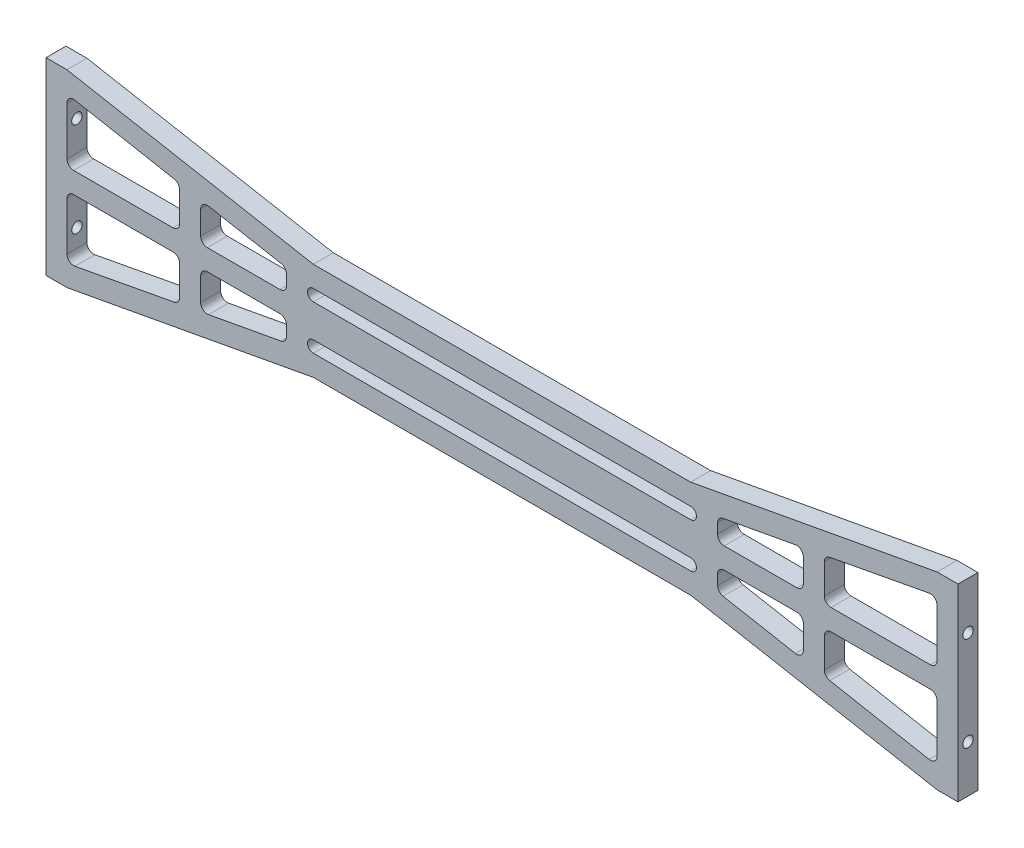
from build123d import *

# Parameters (mm, degrees)
BOSS_EXTRUDE1_DEPTH              = 4.763
TAP_DRILL_FOR_M3X0_5_TAP1_REACH  = 220.74
TAP_DRILL_FOR_M3X0_5_TAP1_BORE_R = 1.25
TAP_DRILL_FOR_M3X0_5_TAP2_REACH  = 220.74
TAP_DRILL_FOR_M3X0_5_TAP2_BORE_R = 1.25


with BuildPart() as part:
    # Sketch3 → Boss-Extrude1 (new body)
    with BuildSketch(Plane.XY):
        Polygon((-108.762998674, 22.483018567), (-108.762998674, -22.516981433), (-103.762998674, -22.516981433), (-45, -11.683163514), (45, -11.683163514), (103.762998674, -22.483018567), (108.762998674, -22.483018567), (108.762998674, 22.516981433), (103.762998674, 22.516981433), (45, 11.683163514), (-45, 11.683163514), (-103.762998674, 22.483018567), align=None)
        with BuildLine():
            Line((-45, -3.923438204), (45, -3.923438204))
            ThreePointArc((45, -3.923438204), (46.379862655, -5.303300859), (45, -6.683163514))
            Line((45, -6.683163514), (-45, -6.683163514))
            ThreePointArc((-45, -6.683163514), (-46.379862655, -5.303300859), (-45, -3.923438204))
        make_face(mode=Mode.SUBTRACT)
        with BuildLine():
            Line((-45, 6.683163514), (45, 6.683163514))
            ThreePointArc((45, 6.683163514), (46.379862655, 5.303300859), (45, 3.923438204))
            Line((45, 3.923438204), (-45, 3.923438204))
            ThreePointArc((-45, 3.923438204), (-46.379862655, 5.303300859), (-45, 6.683163514))
        make_face(mode=Mode.SUBTRACT)
        with BuildLine():
            Line((-103.762998674, 15.571322269), (-103.762998674, 4.07129926))
            ThreePointArc((-103.762998674, 4.07129926), (-103.298030689, 2.948767244), (-102.175498674, 2.48379926))
            Line((-102.175498674, 2.48379926), (-78.468999337, 2.48379926))
            ThreePointArc((-78.468999337, 2.48379926), (-77.346467322, 2.948767244), (-76.881499337, 4.07129926))
            Line((-76.881499337, 4.07129926), (-76.881499337, 11.140532377))
            ThreePointArc((-76.881499337, 11.140532377), (-77.247696598, 12.154719672), (-78.177342953, 12.701010766))
            Line((-78.177342953, 12.701010766), (-101.88384229, 17.131800658))
            ThreePointArc((-101.88384229, 17.131800658), (-103.18968597, 16.792625008), (-103.762998674, 15.571322269))
        make_face(mode=Mode.SUBTRACT)
        with BuildLine():
            Line((-52.721922194, -8.035531504), (-70.003544755, -11.217242177))
            ThreePointArc((-70.003544755, -11.217242177), (-71.306631893, -10.87607345), (-71.878487463, -9.656477863))
            Line((-71.878487463, -9.656477863), (-71.880224509, -4.093745129))
            ThreePointArc((-71.880224509, -4.093745129), (-71.415607074, -2.971067976), (-70.293220307, -2.505749486))
            Line((-70.293220307, -2.505749486), (-52.984228369, -2.500344496))
            ThreePointArc((-52.984228369, -2.500344496), (-51.855362923, -2.971180632), (-51.396324213, -4.104894584))
            Line((-51.396324213, -4.104894584), (-51.421956543, -6.491321636))
            ThreePointArc((-51.421956543, -6.491321636), (-51.794905097, -7.496642951), (-52.721922194, -8.035531504))
        make_face(mode=Mode.SUBTRACT)
        with BuildLine():
            Line((-71.881499337, 9.634032264), (-71.881499337, 4.07129926))
            ThreePointArc((-71.881499337, 4.07129926), (-71.416531352, 2.948767244), (-70.293999337, 2.48379926))
            Line((-70.293999337, 2.48379926), (-52.985006556, 2.48379926))
            ThreePointArc((-52.985006556, 2.48379926), (-51.85628819, 2.954987878), (-51.397603521, 4.088845117))
            Line((-51.397603521, 4.088845117), (-51.423981048, 6.475264048))
            ThreePointArc((-51.423981048, 6.475264048), (-51.79724351, 7.480468855), (-52.724428838, 8.019067907))
            Line((-52.724428838, 8.019067907), (-70.007044093, 11.195381981))
            ThreePointArc((-70.007044093, 11.195381981), (-71.310024632, 10.853806362), (-71.881499337, 9.634032264))
        make_face(mode=Mode.SUBTRACT)
        with BuildLine():
            Line((-78.468219908, -2.508302252), (-102.17471809, -2.515704959))
            ThreePointArc((-102.17471809, -2.515704959), (-103.297104857, -2.981023449), (-103.761722292, -4.103700602))
            Line((-103.761722292, -4.103700602), (-103.758131238, -15.603723051))
            ThreePointArc((-103.758131238, -15.603723051), (-103.184437192, -16.824846705), (-101.878487663, -17.16361457))
            Line((-101.878487663, -17.16361457), (-78.173373062, -12.725422186))
            ThreePointArc((-78.173373062, -12.725422186), (-77.24389734, -12.178840823), (-76.878016792, -11.164539226))
            Line((-76.878016792, -11.164539226), (-76.880224265, -4.095306454))
            ThreePointArc((-76.880224265, -4.095306454), (-77.345542755, -2.972919687), (-78.468219908, -2.508302252))
        make_face(mode=Mode.SUBTRACT)
        with BuildLine():
            Line((103.758131238, -15.603723051), (103.761722292, -4.103700602))
            ThreePointArc((103.761722292, -4.103700602), (103.297104857, -2.981023449), (102.17471809, -2.515704959))
            Line((102.17471809, -2.515704959), (78.468219908, -2.508302252))
            ThreePointArc((78.468219908, -2.508302252), (77.345542755, -2.972919687), (76.880224265, -4.095306454))
            Line((76.880224265, -4.095306454), (76.878016792, -11.164539226))
            ThreePointArc((76.878016792, -11.164539226), (77.24389734, -12.178840823), (78.173373062, -12.725422186))
            Line((78.173373062, -12.725422186), (101.878487663, -17.16361457))
            ThreePointArc((101.878487663, -17.16361457), (103.184437192, -16.824846705), (103.758131238, -15.603723051))
        make_face(mode=Mode.SUBTRACT)
        with BuildLine():
            Line((71.878487463, -9.656477863), (71.880224509, -4.093745129))
            ThreePointArc((71.880224509, -4.093745129), (71.415607074, -2.971067976), (70.293220307, -2.505749486))
            Line((70.293220307, -2.505749486), (52.984228369, -2.500344496))
            ThreePointArc((52.984228369, -2.500344496), (51.855362923, -2.971180632), (51.396324213, -4.104894584))
            Line((51.396324213, -4.104894584), (51.421956543, -6.491321636))
            ThreePointArc((51.421956543, -6.491321636), (51.794905097, -7.496642951), (52.721922194, -8.035531504))
            Line((52.721922194, -8.035531504), (70.003544755, -11.217242177))
            ThreePointArc((70.003544755, -11.217242177), (71.306631893, -10.87607345), (71.878487463, -9.656477863))
        make_face(mode=Mode.SUBTRACT)
        with BuildLine():
            Line((52.719410409, 8.051994317), (70.000038591, 11.239101279))
            ThreePointArc((70.000038591, 11.239101279), (71.3032322, 10.898339477), (71.875468579, 9.67892252))
            Line((71.875468579, 9.67892252), (71.878942671, 4.1161906))
            ThreePointArc((71.878942671, 4.1161906), (71.414675832, 2.993368417), (70.292434422, 2.527699469))
            Line((70.292434422, 2.527699469), (52.983445016, 2.516889488))
            ThreePointArc((52.983445016, 2.516889488), (51.854432599, 2.987373096), (51.395039893, 4.120943651))
            Line((51.395039893, 4.120943651), (51.419927024, 6.507378591))
            ThreePointArc((51.419927024, 6.507378591), (51.792561634, 7.512816316), (52.719410409, 8.051994317))
        make_face(mode=Mode.SUBTRACT)
        with BuildLine():
            Line((78.467432828, 2.532804999), (102.173927542, 2.547610413))
            ThreePointArc((102.173927542, 2.547610413), (103.296168952, 3.013279362), (103.760435791, 4.136101544))
            Line((103.760435791, 4.136101544), (103.753253685, 15.636122311))
            ThreePointArc((103.753253685, 15.636122311), (103.179178352, 16.857066761), (101.873123102, 17.195426807))
            Line((101.873123102, 17.195426807), (78.169395548, 12.749832365))
            ThreePointArc((78.169395548, 12.749832365), (77.24009055, 12.202960786), (76.87452675, 11.188544987))
            Line((76.87452675, 11.188544987), (76.878941696, 4.119313249))
            ThreePointArc((76.878941696, 4.119313249), (77.344610645, 2.997071839), (78.467432828, 2.532804999))
        make_face(mode=Mode.SUBTRACT)
    extrude(amount=BOSS_EXTRUDE1_DEPTH)

    # Tap Drill for M3x0.5 Tap1 bore → Tap Drill for M3x0.5 Tap1 (cut, up to next)
    with BuildSketch(Plane(origin=(108.762998674, 0, 0), x_dir=(0, 0, -1), z_dir=(1, 0, 0)), mode=Mode.PRIVATE) as tap_drill_for_m3x0_5_tap1_sk1:
        with Locations((-2.3815, 11.266981433)):
            Circle(TAP_DRILL_FOR_M3X0_5_TAP1_BORE_R)
    tap_drill_for_m3x0_5_tap1_tool1 = extrude(tap_drill_for_m3x0_5_tap1_sk1.sketch, amount=-TAP_DRILL_FOR_M3X0_5_TAP1_REACH, mode=Mode.PRIVATE) & part.part
    # Tap Drill for M3x0.5 Tap1 bore → Tap Drill for M3x0.5 Tap1 (cut, up to next)
    with BuildSketch(Plane(origin=(108.762998674, 0, 0), x_dir=(0, 0, -1), z_dir=(1, 0, 0)), mode=Mode.PRIVATE) as tap_drill_for_m3x0_5_tap1_sk2:
        with Locations((-2.3815, -11.233018567)):
            Circle(TAP_DRILL_FOR_M3X0_5_TAP1_BORE_R)
    tap_drill_for_m3x0_5_tap1_tool2 = extrude(tap_drill_for_m3x0_5_tap1_sk2.sketch, amount=-TAP_DRILL_FOR_M3X0_5_TAP1_REACH, mode=Mode.PRIVATE) & part.part
    add(tap_drill_for_m3x0_5_tap1_tool1.solids().sort_by_distance((108.762999, 11.266981, 2.3815))[0], mode=Mode.SUBTRACT)
    add(tap_drill_for_m3x0_5_tap1_tool2.solids().sort_by_distance((108.762999, -11.233019, 2.3815))[0], mode=Mode.SUBTRACT)

    # Tap Drill for M3x0.5 Tap2 bore → Tap Drill for M3x0.5 Tap2 (cut, up to next)
    with BuildSketch(Plane.ZY.offset(108.762998674), mode=Mode.PRIVATE) as tap_drill_for_m3x0_5_tap2_sk1:
        with Locations((2.3815, 11.233018567)):
            Circle(TAP_DRILL_FOR_M3X0_5_TAP2_BORE_R)
    tap_drill_for_m3x0_5_tap2_tool1 = extrude(tap_drill_for_m3x0_5_tap2_sk1.sketch, amount=-TAP_DRILL_FOR_M3X0_5_TAP2_REACH, mode=Mode.PRIVATE) & part.part
    # Tap Drill for M3x0.5 Tap2 bore → Tap Drill for M3x0.5 Tap2 (cut, up to next)
    with BuildSketch(Plane.ZY.offset(108.762998674), mode=Mode.PRIVATE) as tap_drill_for_m3x0_5_tap2_sk2:
        with Locations((2.3815, -11.266981433)):
            Circle(TAP_DRILL_FOR_M3X0_5_TAP2_BORE_R)
    tap_drill_for_m3x0_5_tap2_tool2 = extrude(tap_drill_for_m3x0_5_tap2_sk2.sketch, amount=-TAP_DRILL_FOR_M3X0_5_TAP2_REACH, mode=Mode.PRIVATE) & part.part
    add(tap_drill_for_m3x0_5_tap2_tool1.solids().sort_by_distance((-108.762999, 11.233019, 2.3815))[0], mode=Mode.SUBTRACT)
    add(tap_drill_for_m3x0_5_tap2_tool2.solids().sort_by_distance((-108.762999, -11.266981, 2.3815))[0], mode=Mode.SUBTRACT)


solid = part.part
